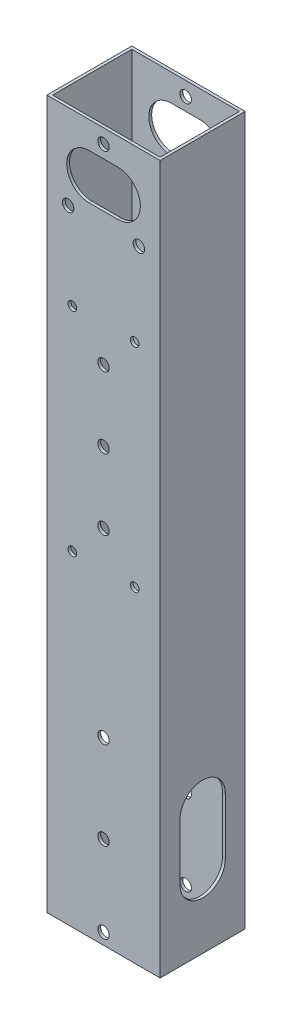
from build123d import *

# Parameters (mm, degrees)
SKETCH_1_W               = 40
SKETCH_1_H               = 30
EXTRUDE_1_DEPTH          = 125
SKETCH_2_W               = 38
SKETCH_2_H               = 28
CUT_EXTRUDE_1_DEPTH      = 126
CUT_EXTRUDE_1_DEPTH_BACK = 126
SKETCH_3_R               = 2.025
CUT_EXTRUDE_2_DEPTH      = 1
CUT_EXTRUDE_2_DEPTH_BACK = 31
SKETCH_4_R               = 2.025
CUT_EXTRUDE_3_DEPTH      = 1
CUT_EXTRUDE_3_DEPTH_BACK = 31
SKETCH_5_R               = 1.525
CUT_EXTRUDE_4_DEPTH      = 31
SKETCH_6_R               = 2.025
CUT_EXTRUDE_5_DEPTH      = 31
CUT_EXTRUDE_6_DEPTH      = 10
SKETCH_8_R               = 3.25
CUT_EXTRUDE_7_DEPTH      = 10
CUT_EXTRUDE_8_DEPTH      = 1
CUT_EXTRUDE_8_DEPTH_BACK = 41
CUT_EXTRUDE_9_DEPTH      = 1
CUT_EXTRUDE_9_DEPTH_BACK = 31


with BuildPart() as part:
    # 草图1 → 凸台-拉伸1 (new body, symmetric)
    with BuildSketch(Plane(origin=(0, 0, 0), x_dir=(1, 0, 0), z_dir=(0, 1, 0))):
        Rectangle(SKETCH_1_W, SKETCH_1_H)
    extrude(amount=EXTRUDE_1_DEPTH, both=True)

    # 草图2 → 切除-拉伸1 (cut, two sides)
    with BuildSketch(Plane(origin=(0, 0, 0), x_dir=(1, 0, 0), z_dir=(0, 1, 0))) as cut_extrude_1_sk:
        Rectangle(SKETCH_2_W, SKETCH_2_H)
    extrude(amount=CUT_EXTRUDE_1_DEPTH, mode=Mode.SUBTRACT)
    extrude(cut_extrude_1_sk.sketch, amount=-CUT_EXTRUDE_1_DEPTH_BACK, mode=Mode.SUBTRACT)

    # 草图3 → 切除-拉伸2 (cut, two sides)
    with BuildSketch(Plane.XY.offset(15)) as cut_extrude_2_sk:
        with Locations((0, -61.5)):
            Circle(SKETCH_3_R)
        with Locations((0, -92.5)):
            Circle(SKETCH_3_R)
        with Locations((0, -121)):
            Circle(SKETCH_3_R)
    extrude(amount=CUT_EXTRUDE_2_DEPTH, mode=Mode.SUBTRACT)
    extrude(cut_extrude_2_sk.sketch, amount=-CUT_EXTRUDE_2_DEPTH_BACK, mode=Mode.SUBTRACT)

    # 草图4 → 切除-拉伸3 (cut, two sides)
    with BuildSketch(Plane(origin=(0, 0, -15), x_dir=(-1, 0, 0), z_dir=(0, 0, -1))) as cut_extrude_3_sk:
        with Locations((0, 120)):
            Circle(SKETCH_4_R)
        with Locations((-12.5, 95)):
            Circle(SKETCH_4_R)
        with Locations((12.5, 95)):
            Circle(SKETCH_4_R)
    extrude(amount=CUT_EXTRUDE_3_DEPTH, mode=Mode.SUBTRACT)
    extrude(cut_extrude_3_sk.sketch, amount=-CUT_EXTRUDE_3_DEPTH_BACK, mode=Mode.SUBTRACT)

    # 草图5 → 切除-拉伸4 (cut, through all)
    with BuildSketch(Plane(origin=(0, 0, -15), x_dir=(-1, 0, 0), z_dir=(0, 0, -1))):
        with Locations((-11, 65)):
            Circle(SKETCH_5_R)
        with Locations((11, 65)):
            Circle(SKETCH_5_R)
        with Locations((-11, -10)):
            Circle(SKETCH_5_R)
        with Locations((11, -10)):
            Circle(SKETCH_5_R)
    extrude(amount=-CUT_EXTRUDE_4_DEPTH, mode=Mode.SUBTRACT)

    # 草图6 → 切除-拉伸5 (cut, through all)
    with BuildSketch(Plane(origin=(0, 0, -15), x_dir=(-1, 0, 0), z_dir=(0, 0, -1))):
        with Locations((0, 27.5)):
            Circle(SKETCH_6_R)
        with Locations((0, 52.5)):
            Circle(SKETCH_6_R)
        with Locations((0, 2.5)):
            Circle(SKETCH_6_R)
    extrude(amount=-CUT_EXTRUDE_5_DEPTH, mode=Mode.SUBTRACT)

    # 草图7 → 切除-拉伸6 (cut)
    with BuildSketch(Plane(origin=(0, 0, -15), x_dir=(-1, 0, 0), z_dir=(0, 0, -1))):
        with BuildLine():
            Line((7, 52.5), (7, 2.5))
            ThreePointArc((7, 2.5), (0, -4.5), (-7, 2.5))
            Line((-7, 2.5), (-7, 52.5))
            ThreePointArc((-7, 52.5), (0, 59.5), (7, 52.5))
        make_face()
    extrude(amount=-CUT_EXTRUDE_6_DEPTH, mode=Mode.SUBTRACT)

    # 草图8 → 切除-拉伸7 (cut)
    with BuildSketch(Plane(origin=(0, 0, -15), x_dir=(-1, 0, 0), z_dir=(0, 0, -1))):
        with Locations((11, 65)):
            Circle(SKETCH_8_R)
        with Locations((-11, 65)):
            Circle(SKETCH_8_R)
        with Locations((11, -10)):
            Circle(SKETCH_8_R)
        with Locations((-11, -10)):
            Circle(SKETCH_8_R)
    extrude(amount=-CUT_EXTRUDE_7_DEPTH, mode=Mode.SUBTRACT)

    # 草图9 → 切除-拉伸8 (cut, two sides)
    with BuildSketch(Plane(origin=(20, 0, 0), x_dir=(0, 0, -1), z_dir=(1, 0, 0))) as cut_extrude_8_sk:
        with BuildLine():
            Line((-8, -100), (-8, -80))
            ThreePointArc((-8, -80), (0, -72), (8, -80))
            Line((8, -80), (8, -100))
            ThreePointArc((8, -100), (0, -108), (-8, -100))
        make_face()
    extrude(amount=CUT_EXTRUDE_8_DEPTH, mode=Mode.SUBTRACT)
    extrude(cut_extrude_8_sk.sketch, amount=-CUT_EXTRUDE_8_DEPTH_BACK, mode=Mode.SUBTRACT)

    # 草图10 → 切除-拉伸9 (cut, two sides)
    with BuildSketch(Plane(origin=(0, 0, -15), x_dir=(-1, 0, 0), z_dir=(0, 0, -1))) as cut_extrude_9_sk:
        with BuildLine():
            Line((-5, 115.5), (5, 115.5))
            ThreePointArc((5, 115.5), (13, 107.5), (5, 99.5))
            Line((5, 99.5), (-5, 99.5))
            ThreePointArc((-5, 99.5), (-13, 107.5), (-5, 115.5))
        make_face()
    extrude(amount=CUT_EXTRUDE_9_DEPTH, mode=Mode.SUBTRACT)
    extrude(cut_extrude_9_sk.sketch, amount=-CUT_EXTRUDE_9_DEPTH_BACK, mode=Mode.SUBTRACT)


solid = part.part
